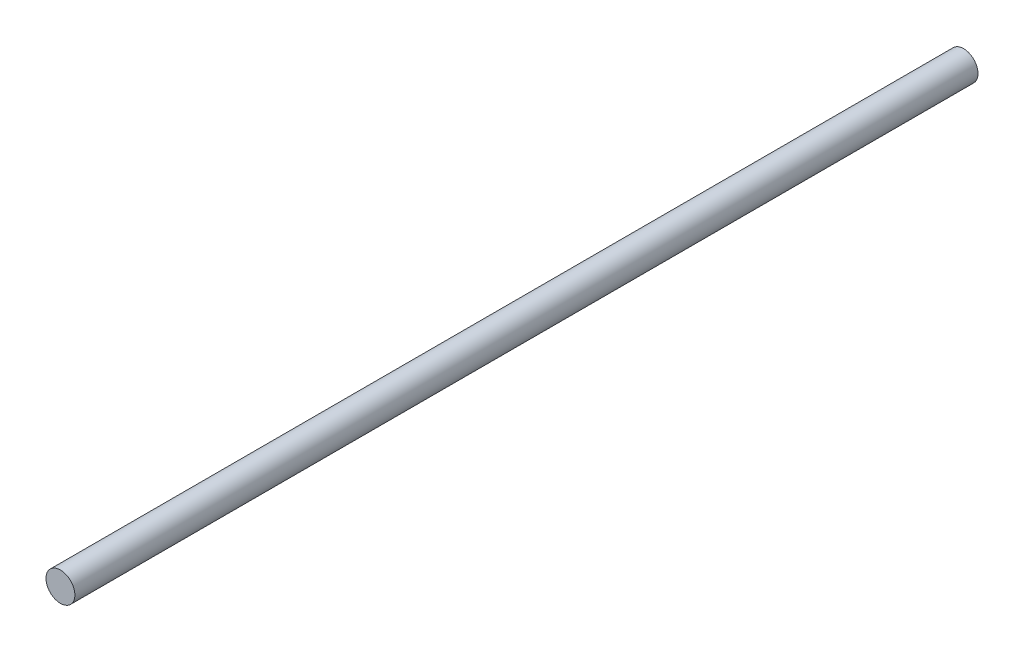
from build123d import *

# Parameters (mm, degrees)
SKETCH_1_R      = 6
EXTRUDE_1_DEPTH = 375


with BuildPart() as part:
    # 草图1 → 凸台-拉伸1 (new body)
    with BuildSketch(Plane.XY):
        Circle(SKETCH_1_R)
    extrude(amount=EXTRUDE_1_DEPTH)


solid = part.part
